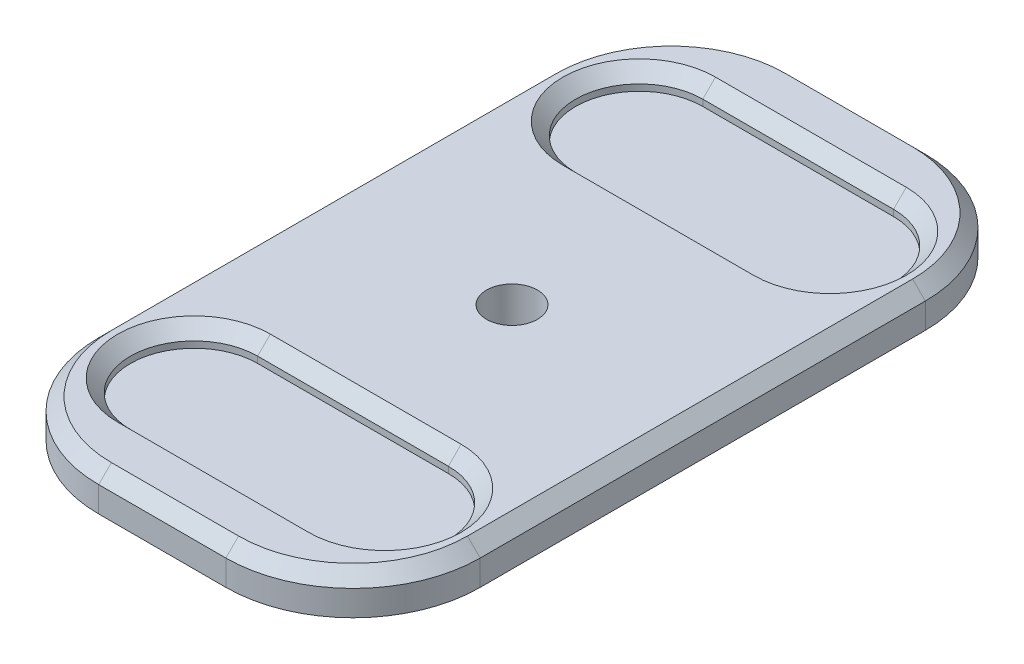
from build123d import *

# Parameters (mm, degrees)
SKETCH1_W           = 60
SKETCH1_H           = 70
BOSS_EXTRUDE1_DEPTH = 3
SKETCH2_W           = 60
SKETCH2_H           = 140
BOSS_EXTRUDE2_DEPTH = 3
SKETCH4_W           = 60
SKETCH4_H           = 5
CUT_EXTRUDE1_DEPTH  = 10
CHAMFER2_SIZE       = 15
SKETCH5_R           = 4
CUT_EXTRUDE2_DEPTH  = 3
FILLET3_R           = 20
CHAMFER3_SIZE       = 1
SKETCH6_W           = 103.197432935
SKETCH6_H           = 87.20183083
CUT_EXTRUDE3_DEPTH  = 100
SKETCH7_W           = 60
SKETCH7_H           = 55
BOSS_EXTRUDE3_DEPTH = 3
SKETCH8_W           = 60
SKETCH8_H           = 55
BOSS_EXTRUDE4_DEPTH = 3
FILLET4_R           = 20
CHAMFER4_SIZE       = 2
SKETCH9_R           = 4
CUT_EXTRUDE4_DEPTH  = 10


with BuildPart() as part:
    # Sketch1 → Boss-Extrude1 (new body)
    with BuildSketch(Plane(origin=(0, 0, 0), x_dir=(1, 0, 0), z_dir=(0, 1, 0))):
        with Locations((0, -35)):
            Rectangle(SKETCH1_W, SKETCH1_H)
        with BuildLine():
            Line((-15, -35), (15, -35))
            ThreePointArc((15, -35), (25, -25), (15, -15))
            Line((15, -15), (-15, -15))
            ThreePointArc((-15, -15), (-25, -25), (-15, -35))
        make_face(mode=Mode.SUBTRACT)
    boss_extrude1 = extrude(amount=BOSS_EXTRUDE1_DEPTH)

    # Mirror1: Boss-Extrude1 across plane
    add(boss_extrude1.mirror(Plane(origin=(-30, 3, 70), x_dir=(1, 0, 0), z_dir=(0, 0, -1))))

    # Sketch2 → Boss-Extrude2 (add)
    with BuildSketch(Plane(origin=(0, 0, 0), x_dir=(-1, 0, 0), z_dir=(0, -1, 0))):
        with Locations((0, -70)):
            Rectangle(SKETCH2_W, SKETCH2_H)
    boss_extrude2 = extrude(amount=BOSS_EXTRUDE2_DEPTH)

    # Sketch4 → Cut-Extrude1 (cut)
    with BuildSketch(Plane(origin=(0, 3, 0), x_dir=(1, 0, 0), z_dir=(0, 1, 0))):
        with Locations((0, -2.5)):
            Rectangle(SKETCH4_W, SKETCH4_H)
        with Locations((0, -137.5)):
            Rectangle(SKETCH4_W, SKETCH4_H)
    cut_extrude1 = extrude(amount=-CUT_EXTRUDE1_DEPTH, mode=Mode.SUBTRACT)

    # Chamfer2
    chamfer2_edges = [part.edges().sort_by_distance(p)[0] for p in [
        (30, 0, 5),
        (-30, 0, 5),
        (30, 0, 135),
        (-30, 0, 135),
    ]]
    chamfer(chamfer2_edges, length=CHAMFER2_SIZE)

    # Sketch5 → Cut-Extrude2 (cut)
    with BuildSketch(Plane.XZ.offset(3)):
        with Locations((0, 70)):
            Circle(SKETCH5_R)
    extrude(amount=-CUT_EXTRUDE2_DEPTH, mode=Mode.SUBTRACT)

    # Fillet3
    fillet3_edges = [part.edges().sort_by_distance(p)[0] for p in [
        (-30, 0, 20),
        (-30, 0, 120),
        (15, 0, 135),
        (-15, 0, 135),
        (30, 0, 20),
        (30, 0, 120),
        (-15, 0, 5),
        (15, 0, 5),
    ]]
    fillet(fillet3_edges, radius=FILLET3_R)

    # Chamfer3
    chamfer3_edges = [part.edges().sort_by_distance(p)[0] for p in [
        (25, 3, 25),
        (0, 3, 15),
        (-25, 3, 25),
        (0, 3, 35),
        (30, 3, 70),
        (-30, 3, 70),
        (-22.5, 3, 127.5),
        (0, 3, 135),
        (22.5, 3, 127.5),
        (22.5, 3, 12.5),
        (0, 3, 5),
        (-22.5, 3, 12.5),
        (-14.3693974, 3, 133.47759065),
        (-28.47759065, 3, 119.3693974),
        (14.3693974, 3, 133.47759065),
        (28.47759065, 3, 119.3693974),
        (-28.47759065, 3, 20.6306026),
        (-14.3693974, 3, 6.52240935),
        (14.3693974, 3, 6.52240935),
        (28.47759065, 3, 20.6306026),
        (25, 3, 115),
        (0, 3, 125),
        (-25, 3, 115),
        (0, 3, 105),
    ]]
    chamfer(chamfer3_edges, length=CHAMFER3_SIZE)

    # Sketch6 → Cut-Extrude3 (cut)
    with BuildSketch(Plane(origin=(0, 3, 0), x_dir=(1, 0, 0), z_dir=(0, 1, 0))):
        with Locations((0.064498395, -103.600915415)):
            Rectangle(SKETCH6_W, SKETCH6_H)
    cut_extrude3 = extrude(amount=-CUT_EXTRUDE3_DEPTH, mode=Mode.SUBTRACT)

    # Mirror4: Boss-Extrude1, Boss-Extrude2, Cut-Extrude1, Cut-Extrude3 across plane
    add(boss_extrude1.mirror(Plane(origin=(-51.534218072, -97, 60), x_dir=(1, 0, 0), z_dir=(0, 0, -1))))
    add(boss_extrude2.mirror(Plane(origin=(-51.534218072, -97, 60), x_dir=(1, 0, 0), z_dir=(0, 0, -1))))
    add(cut_extrude1.mirror(Plane(origin=(-51.534218072, -97, 60), x_dir=(1, 0, 0), z_dir=(0, 0, -1))), mode=Mode.SUBTRACT)
    add(cut_extrude3.mirror(Plane(origin=(-51.534218072, -97, 60), x_dir=(1, 0, 0), z_dir=(0, 0, -1))), mode=Mode.SUBTRACT)

    # Sketch7 → Boss-Extrude3 (add)
    with BuildSketch(Plane(origin=(0, 3, 0), x_dir=(1, 0, 0), z_dir=(0, 1, 0))):
        with Locations((0, -32.5)):
            Rectangle(SKETCH7_W, SKETCH7_H)
        with BuildLine():
            Line((-15, -35), (15, -35))
            ThreePointArc((15, -35), (25, -25), (15, -15))
            Line((15, -15), (-15, -15))
            ThreePointArc((-15, -15), (-25, -25), (-15, -35))
        make_face(mode=Mode.SUBTRACT)
    extrude(amount=-BOSS_EXTRUDE3_DEPTH)

    # Sketch8 → Boss-Extrude4 (add)
    with BuildSketch(Plane(origin=(0, 0, 0), x_dir=(-1, 0, 0), z_dir=(0, -1, 0))):
        with Locations((0, -32.5)):
            Rectangle(SKETCH8_W, SKETCH8_H)
    extrude(amount=BOSS_EXTRUDE4_DEPTH)

    # Fillet4
    fillet4_edges = [part.edges().sort_by_distance(p)[0] for p in [
        (30, 0, 115),
        (-30, 0, 115),
        (-30, 0, 5),
        (30, 0, 5),
    ]]
    fillet(fillet4_edges, radius=FILLET4_R)

    # Chamfer4
    chamfer4_edges = [part.edges().sort_by_distance(p)[0] for p in [
        (25, 3, 95),
        (0, 3, 105),
        (-25, 3, 95),
        (0, 3, 85),
        (-25, 3, 25),
        (0, 3, 15),
        (25, 3, 25),
        (0, 3, 35),
        (0, 3, 115),
        (30, 3, 60),
        (0, 3, 5),
        (-30, 3, 60),
        (-24.142135624, 3, 10.857864376),
        (24.142135624, 3, 10.857864376),
        (-24.142135624, 3, 109.142135624),
        (24.142135624, 3, 109.142135624),
    ]]
    chamfer(chamfer4_edges, length=CHAMFER4_SIZE)

    # Sketch9 → Cut-Extrude4 (cut)
    with BuildSketch(Plane(origin=(0, -3, 0), x_dir=(-1, 0, 0), z_dir=(0, -1, 0))):
        with Locations((0, -60)):
            Circle(SKETCH9_R)
    extrude(amount=-CUT_EXTRUDE4_DEPTH, mode=Mode.SUBTRACT)


solid = part.part
